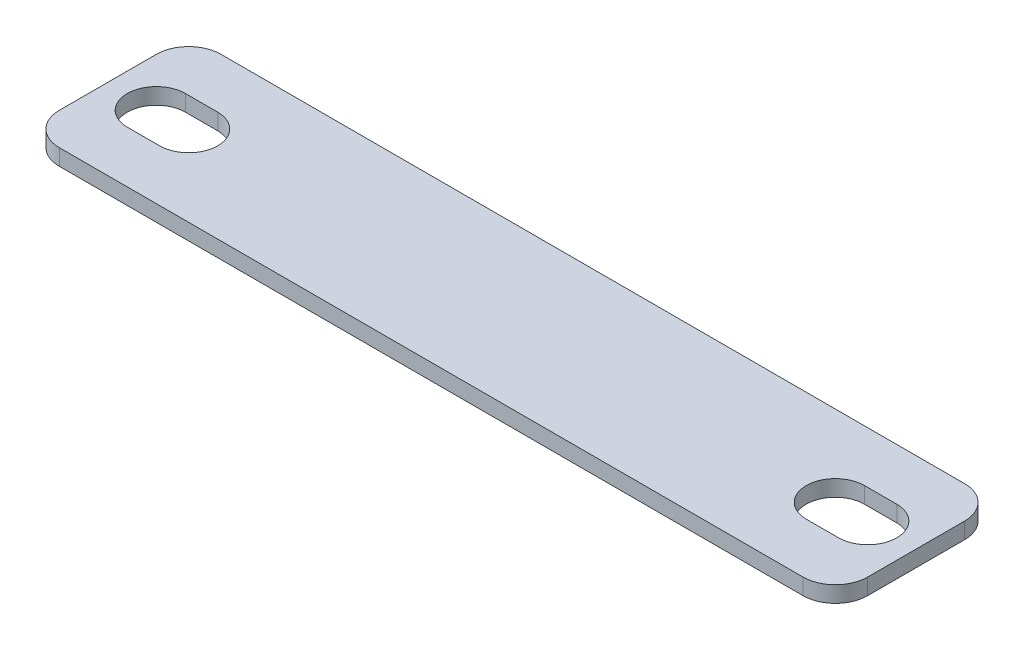
from build123d import *

# Parameters (mm, degrees)
SKETCH1_W           = 63.5
SKETCH1_H           = 12.7
BOSS_EXTRUDE1_DEPTH = 1.27
FILLET1_R           = 2.54


with BuildPart() as part:
    # Sketch1 → Boss-Extrude1 (new body)
    with BuildSketch(Plane(origin=(0, 0, 0), x_dir=(1, 0, 0), z_dir=(0, 1, 0))):
        Rectangle(SKETCH1_W, SKETCH1_H)
        with BuildLine():
            Line((25.4, 2.286), (27.94, 2.286))
            ThreePointArc((27.94, 2.286), (30.226, 0), (27.94, -2.286))
            Line((27.94, -2.286), (25.4, -2.286))
            ThreePointArc((25.4, -2.286), (23.114, 0), (25.4, 2.286))
        make_face(mode=Mode.SUBTRACT)
        with BuildLine():
            Line((-27.94, 2.286), (-25.4, 2.286))
            ThreePointArc((-25.4, 2.286), (-23.114, 0), (-25.4, -2.286))
            Line((-25.4, -2.286), (-27.94, -2.286))
            ThreePointArc((-27.94, -2.286), (-30.226, 0), (-27.94, 2.286))
        make_face(mode=Mode.SUBTRACT)
    extrude(amount=BOSS_EXTRUDE1_DEPTH)

    # Fillet1
    fillet1_edges = [part.edges().sort_by_distance(p)[0] for p in [
        (-31.75, 0.635, -6.35),
        (31.75, 0.635, -6.35),
        (31.75, 0.635, 6.35),
        (-31.75, 0.635, 6.35),
    ]]
    fillet(fillet1_edges, radius=FILLET1_R)


solid = part.part
